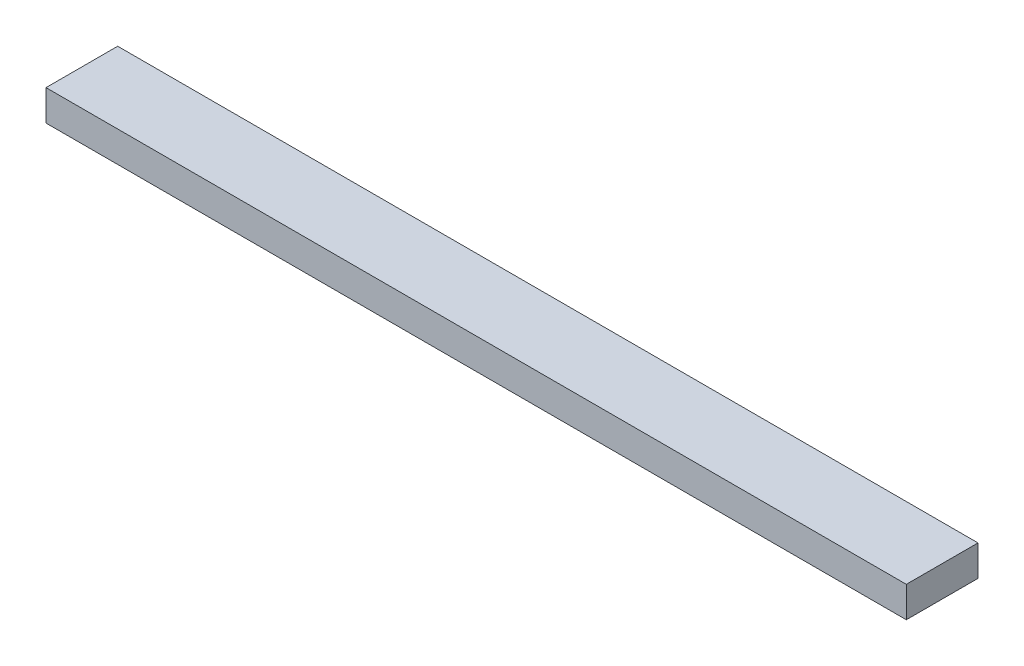
from build123d import *

# Parameters (mm, degrees)
SKETCH1_W           = 1066.8
SKETCH1_H           = 88.9
BOSS_EXTRUDE1_DEPTH = 38.1


with BuildPart() as part:
    # Sketch1 → Boss-Extrude1 (new body)
    with BuildSketch(Plane(origin=(0, 0, 0), x_dir=(1, 0, 0), z_dir=(0, 1, 0))):
        with Locations((533.4, 44.45)):
            Rectangle(SKETCH1_W, SKETCH1_H)
    extrude(amount=BOSS_EXTRUDE1_DEPTH)


solid = part.part
